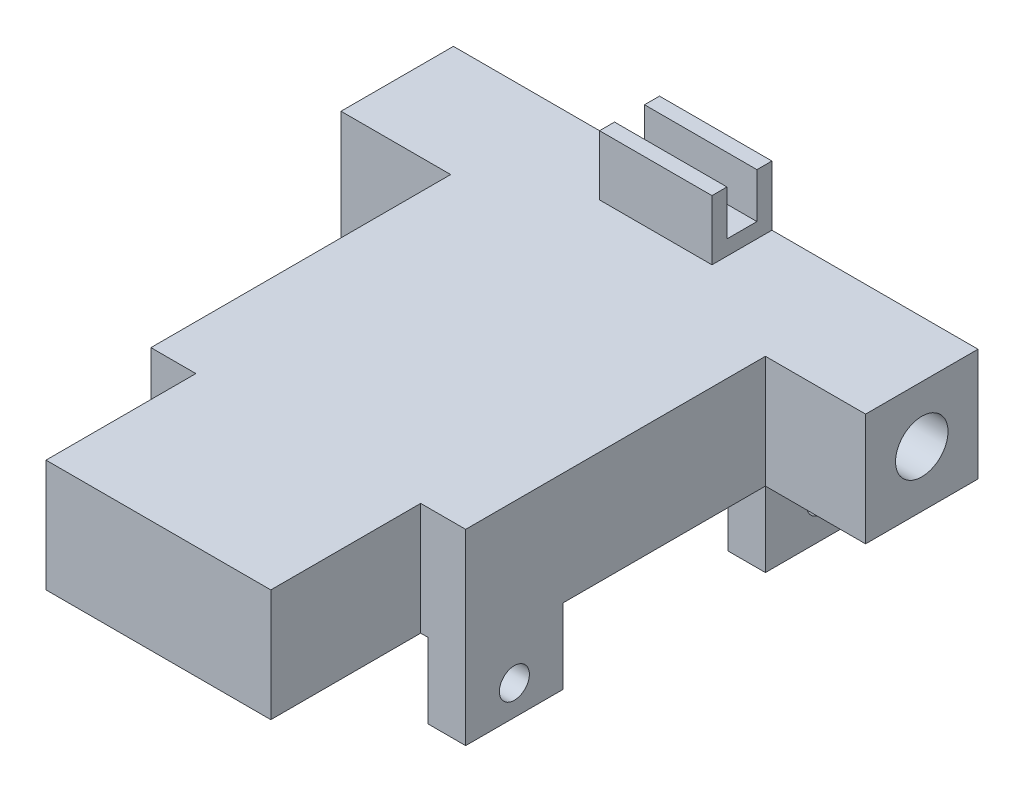
from build123d import *

# Parameters (mm, degrees)
SKETCH1_W           = 88.9
SKETCH1_H           = 19.05
BOSS_EXTRUDE1_DEPTH = 19.05
SKETCH2_W           = 6.35
SKETCH2_H           = 19.05
BOSS_EXTRUDE2_DEPTH = 12.7
SKETCH3_R           = 4.445
CUT_EXTRUDE1_DEPTH  = 96.266
SKETCH4_R           = 2.54
CUT_EXTRUDE2_DEPTH  = 96.266
SKETCH5_W           = 53.34
SKETCH5_H           = 19.05
BOSS_EXTRUDE3_DEPTH = 50.8
SKETCH6_W           = 6.35
SKETCH6_H           = 16.51
BOSS_EXTRUDE4_DEPTH = 12.7
SKETCH7_R           = 2.54
CUT_EXTRUDE3_DEPTH  = 61.976
SKETCH8_W           = 19.05
SKETCH8_H           = 10.16
BOSS_EXTRUDE5_DEPTH = 2.54
SKETCH9_W           = 19.05
SKETCH9_H           = 2.54
BOSS_EXTRUDE6_DEPTH = 7.62
SKETCH10_W          = 38.1
SKETCH10_H          = 19.05
BOSS_EXTRUDE7_DEPTH = 25.4
SKETCH11_R          = 6.35
CUT_EXTRUDE4_DEPTH  = 12.7


with BuildPart() as part:
    # Sketch1 → Boss-Extrude1 (new body)
    with BuildSketch(Plane.XY):
        with Locations((44.45, -9.525)):
            Rectangle(SKETCH1_W, SKETCH1_H)
    extrude(amount=BOSS_EXTRUDE1_DEPTH)

    # Sketch2 → Boss-Extrude2 (add)
    with BuildSketch(Plane.XZ.offset(19.05)):
        with Locations((21.758870797, 9.525)):
            Rectangle(SKETCH2_W, SKETCH2_H)
        with Locations((68.748870797, 9.525)):
            Rectangle(SKETCH2_W, SKETCH2_H)
    extrude(amount=BOSS_EXTRUDE2_DEPTH)

    # Sketch3 → Cut-Extrude1 (cut)
    with BuildSketch(Plane.ZY):
        with Locations((9.525, -9.525)):
            Circle(SKETCH3_R)
    extrude(amount=-CUT_EXTRUDE1_DEPTH, mode=Mode.SUBTRACT)

    # Sketch4 → Cut-Extrude2 (cut)
    with BuildSketch(Plane.ZY.offset(-18.583870797)):
        with Locations((9.525, -25.4)):
            Circle(SKETCH4_R)
    extrude(amount=-CUT_EXTRUDE2_DEPTH, mode=Mode.SUBTRACT)

    # Sketch5 → Boss-Extrude3 (add)
    with BuildSketch(Plane.XY.offset(19.05)):
        with Locations((45.253870797, -9.525)):
            Rectangle(SKETCH5_W, SKETCH5_H)
    extrude(amount=BOSS_EXTRUDE3_DEPTH)

    # Sketch6 → Boss-Extrude4 (add)
    with BuildSketch(Plane.XZ.offset(19.05)):
        with Locations((21.758870797, 61.595)):
            Rectangle(SKETCH6_W, SKETCH6_H)
        with Locations((68.748870797, 61.595)):
            Rectangle(SKETCH6_W, SKETCH6_H)
    extrude(amount=BOSS_EXTRUDE4_DEPTH)

    # Sketch7 → Cut-Extrude3 (cut)
    with BuildSketch(Plane.ZY.offset(-18.583870797)):
        with Locations((61.595, -26.67)):
            Circle(SKETCH7_R)
    extrude(amount=-CUT_EXTRUDE3_DEPTH, mode=Mode.SUBTRACT)

    # Sketch8 → Boss-Extrude5 (add)
    with BuildSketch(Plane(origin=(0, 0, 0), x_dir=(1, 0, 0), z_dir=(0, 1, 0))):
        with Locations((44.45, -5.08)):
            Rectangle(SKETCH8_W, SKETCH8_H)
    extrude(amount=BOSS_EXTRUDE5_DEPTH)

    # Sketch9 → Boss-Extrude6 (add)
    with BuildSketch(Plane(origin=(0, 2.54, 0), x_dir=(1, 0, 0), z_dir=(0, 1, 0))):
        with Locations((44.45, -1.27)):
            Rectangle(SKETCH9_W, SKETCH9_H)
        with Locations((44.45, -8.89)):
            Rectangle(SKETCH9_W, SKETCH9_H)
    extrude(amount=BOSS_EXTRUDE6_DEPTH)

    # Sketch10 → Boss-Extrude7 (add)
    with BuildSketch(Plane.XY.offset(69.85)):
        with Locations((45.253870797, -9.525)):
            Rectangle(SKETCH10_W, SKETCH10_H)
    extrude(amount=BOSS_EXTRUDE7_DEPTH)

    # Sketch11 → Cut-Extrude4 (cut)
    with BuildSketch(Plane.ZY.offset(-26.203870797)):
        with Locations((82.55, -9.525)):
            Circle(SKETCH11_R)
    extrude(amount=-CUT_EXTRUDE4_DEPTH, mode=Mode.SUBTRACT)


solid = part.part
